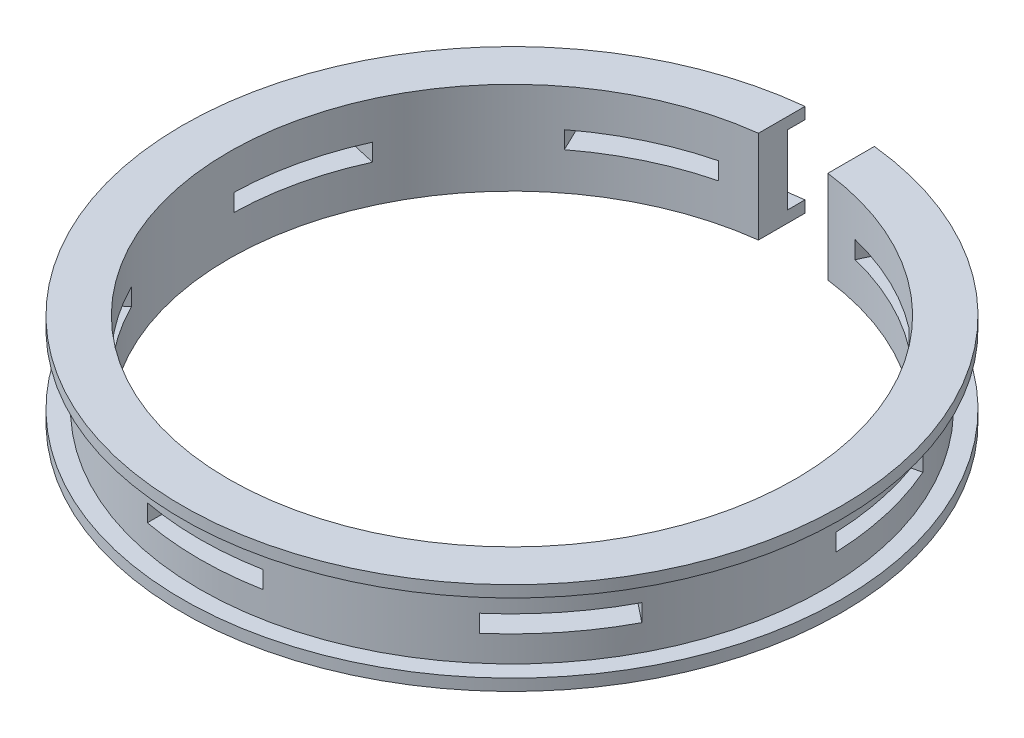
from build123d import *

# Parameters (mm, degrees)
SKETCH_2_W               = 6
SKETCH_2_H               = 57
CUT_EXTRUDE_1_DEPTH      = 9
SKETCH_3_W               = 10
SKETCH_3_H               = 1.5
CUT_EXTRUDE_2_DEPTH      = 29.5
PATTERN_CIRCULAR_1_COUNT = 7


with BuildPart() as part:
    # Эскиз1 → Повернуть1 (revolve)
    with BuildSketch(Plane.XY):
        Polygon((24.5, 0), (24.5, 8), (28.5, 8), (28.5, 7), (27, 7), (27, 1), (28.5, 1), (28.5, 0), align=None)
    revolve(axis=Axis((0, 0, 0), (0, 1, 0)))

    # Эскиз2 → Вырез-Вытянуть1 (cut, through all)
    with BuildSketch(Plane(origin=(0, 0, 0), x_dir=(1, 0, 0), z_dir=(0, 1, 0))):
        with Locations((0, 28.5)):
            Rectangle(SKETCH_2_W, SKETCH_2_H)
    extrude(amount=CUT_EXTRUDE_1_DEPTH, mode=Mode.SUBTRACT)

    # Эскиз3 → Вырез-Вытянуть2 (cut, through all)
    with BuildSketch(Plane.XY):
        with Locations((0, 4)):
            Rectangle(SKETCH_3_W, SKETCH_3_H)
    cut_extrude_2 = extrude(amount=CUT_EXTRUDE_2_DEPTH, mode=Mode.SUBTRACT)

    # Круговой массив1: Вырез-Вытянуть2 ×7 about axis
    pattern_circular_1_axis = Axis((0, 0, 0), (0, 1, 0))
    for i in range(1, PATTERN_CIRCULAR_1_COUNT):
        add(cut_extrude_2.rotate(pattern_circular_1_axis, i * 360 / PATTERN_CIRCULAR_1_COUNT), mode=Mode.SUBTRACT)


solid = part.part
